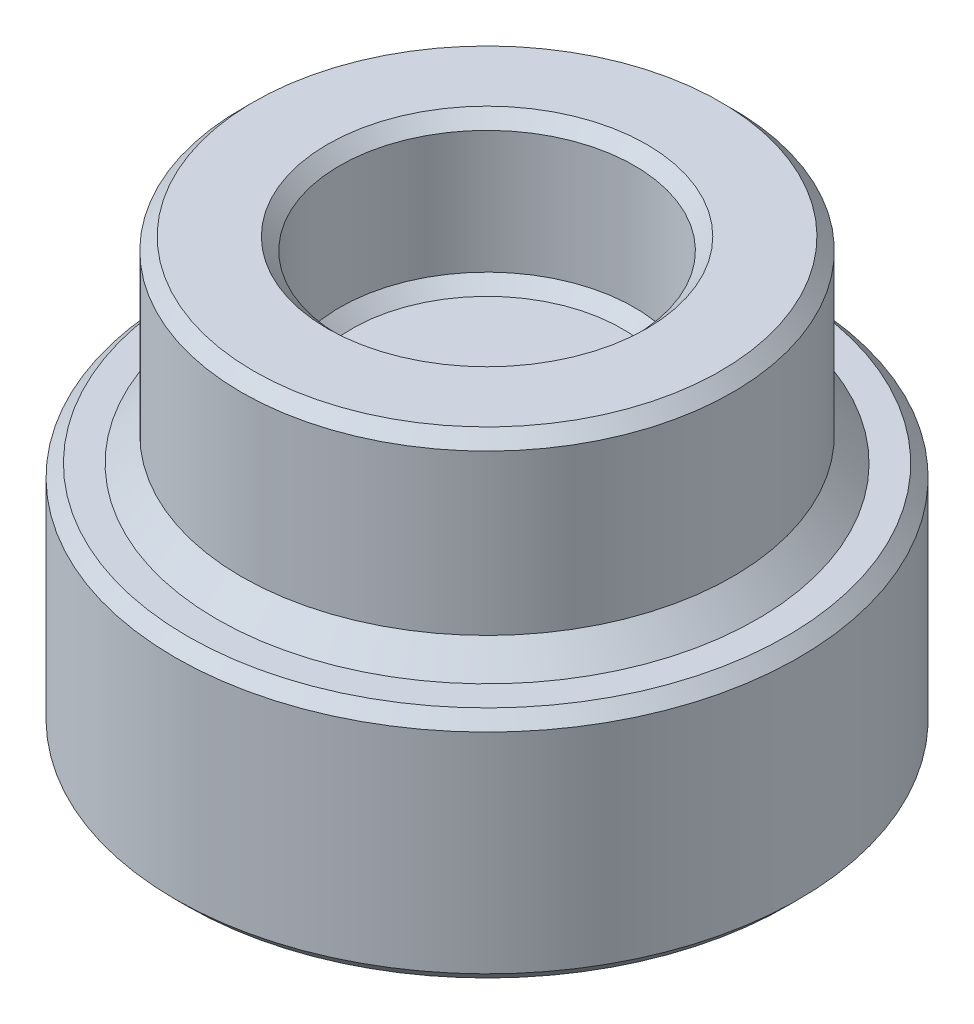
from build123d import *

# Parameters (mm, degrees)
SKETCH1_R                            = 5
BOSS_EXTRUDE1_DEPTH                  = 1
SKETCH1_3_R                          = 5
SKETCH1_3_R_2                        = 3
BOSS_EXTRUDE2_DEPTH                  = 4
CHAMFER1_SIZE                        = 0.25
SKETCH5_R                            = 6.35
BOSS_EXTRUDE4_DEPTH                  = 4.7625
F_3_5_3_5_DIAMETER_HOLE1_D           = 3.5
F_3_5_3_5_DIAMETER_HOLE1_DEPTH       = 4.451427784
F_3_5_3_5_DIAMETER_HOLE1_CSINK_D     = 4
F_3_5_3_5_DIAMETER_HOLE1_CSINK_ANGLE = 90
F_3_5_3_5_DIAMETER_HOLE1_TIP         = 0.308572216
CHAMFER2_SIZE                        = 0.25
CHAMFER3_SIZE                        = 0.5


with BuildPart() as part:
    # Sketch1 → Boss-Extrude1 (new body)
    with BuildSketch(Plane(origin=(0, 0, 0), x_dir=(1, 0, 0), z_dir=(0, 1, 0))):
        Circle(SKETCH1_R)
    extrude(amount=BOSS_EXTRUDE1_DEPTH)

    # Sketch1_3 → Boss-Extrude2 (add)
    with BuildSketch(Plane(origin=(0, 0, 0), x_dir=(1, 0, 0), z_dir=(0, 1, 0))):
        Circle(SKETCH1_3_R)
        Circle(SKETCH1_3_R_2, mode=Mode.SUBTRACT)
    extrude(amount=BOSS_EXTRUDE2_DEPTH)

    # Chamfer1
    chamfer1_edges = [part.edges().sort_by_distance(p)[0] for p in [
        (-3, 4, 0),
        (-5, 4, 0),
        (-3, 1, 0),
    ]]
    chamfer(chamfer1_edges, length=CHAMFER1_SIZE)

    # Sketch5 → Boss-Extrude4 (add)
    with BuildSketch(Plane(origin=(0, 0, 0), x_dir=(1, 0, 0), z_dir=(0, 1, 0))):
        Circle(SKETCH5_R)
    extrude(amount=-BOSS_EXTRUDE4_DEPTH)

    # Ø3.5 (3.5) Diameter Hole1
    with Locations(Plane(origin=(0, -4.7625, 0), x_dir=(-1, 0, 0), z_dir=(0, -1, 0))):
        with Locations((0, 0)):
            CounterSinkHole(F_3_5_3_5_DIAMETER_HOLE1_D / 2, F_3_5_3_5_DIAMETER_HOLE1_CSINK_D / 2, depth=F_3_5_3_5_DIAMETER_HOLE1_DEPTH, counter_sink_angle=F_3_5_3_5_DIAMETER_HOLE1_CSINK_ANGLE)
            with Locations((0, 0, -(F_3_5_3_5_DIAMETER_HOLE1_DEPTH + F_3_5_3_5_DIAMETER_HOLE1_TIP / 2))):  # 160° drill point
                Cone(0, F_3_5_3_5_DIAMETER_HOLE1_D / 2, F_3_5_3_5_DIAMETER_HOLE1_TIP, mode=Mode.SUBTRACT)

    # Chamfer2
    chamfer2_edges = [part.edges().sort_by_distance(p)[0] for p in [
        (-6.35, -4.7625, 0),
        (-6.35, 0, 0),
    ]]
    chamfer(chamfer2_edges, length=CHAMFER2_SIZE)

    # Chamfer3
    chamfer3_edges = [part.edges().sort_by_distance(p)[0] for p in [
        (-5, 0, 0),
    ]]
    chamfer(chamfer3_edges, length=CHAMFER3_SIZE)


solid = part.part
